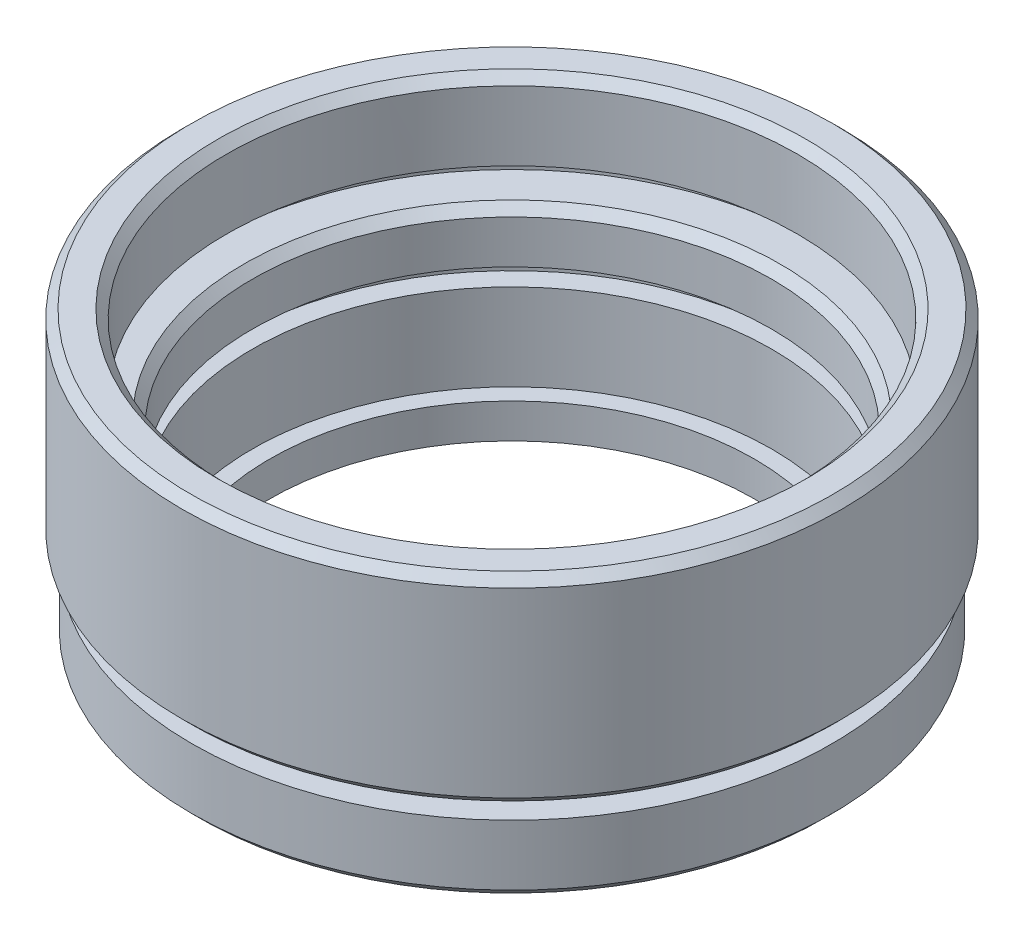
from build123d import *

# Parameters (mm, degrees)
CHAMFER_1_SIZE = 0.5


with BuildPart() as part:
    # 草图1 → 旋转1 (revolve)
    with BuildSketch(Plane.XY, mode=Mode.PRIVATE) as revolve_1_sk:
        Polygon((14, 0), (14, 2), (15, 2), (15, 7), (16.15, 7), (16.15, 8), (15, 8), (15, 11), (17.65, 11), (17.65, 12), (16.5, 12), (16.5, 16.5), (18.55, 16.5), (19.05, 16), (19.05, 5.5), (18.55, 5), (17, 5), (17, 4), (18.5, 4), (18.5, 0.5), (18, 0), align=None)
    revolve(revolve_1_sk.sketch.rotate(Axis((0, 0, 0), (0, 1, 0)), 90), axis=Axis((0, 0, 0), (0, 1, 0)))  # turned: the seam where the file's is

    # 倒角1
    chamfer_1_edges = [part.edges().sort_by_distance(p)[0] for p in [
        (0, 11, 15),
        (0, 16.5, 16.5),
    ]]
    chamfer(chamfer_1_edges, length=CHAMFER_1_SIZE)


solid = part.part
